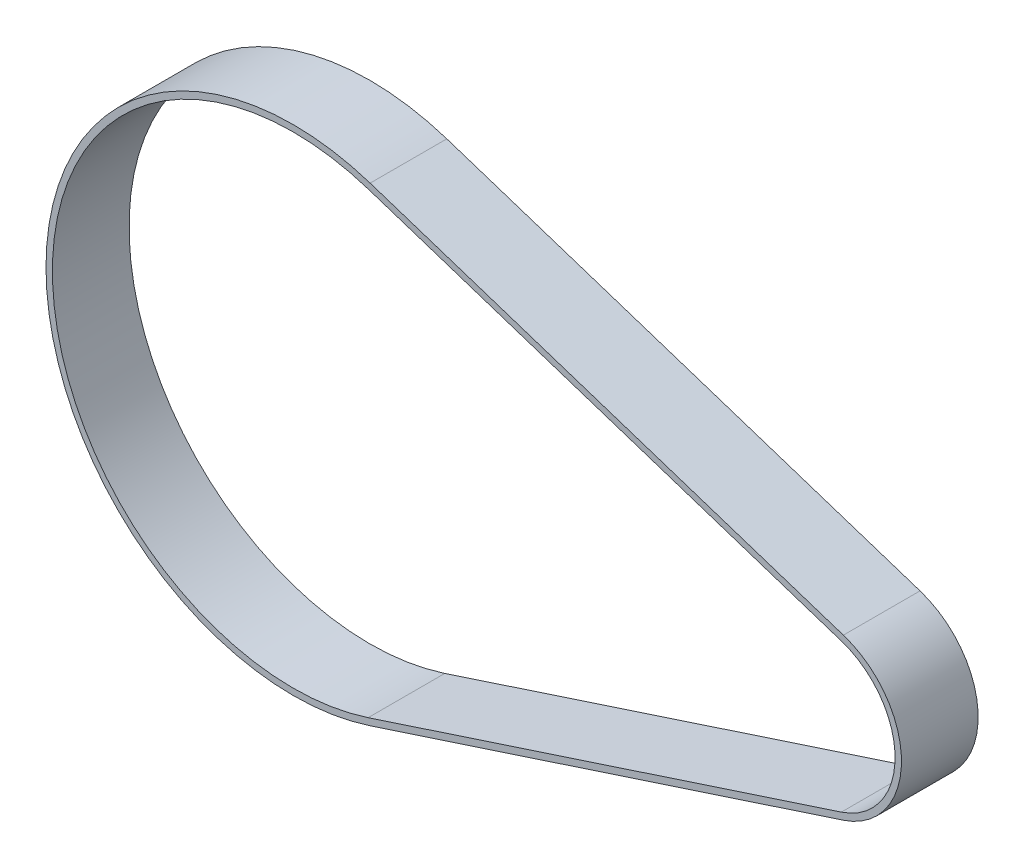
from build123d import *

# Parameters (mm, degrees)
SALIENTE_EXTRUIR1_DEPTH = 6


with BuildPart() as part:
    # Croquis1 → Saliente-Extruir1 (new body)
    with BuildSketch(Plane.XY):
        with BuildLine():
            Line((43.052439024, -6.27275809), (6.017378049, -18.390586217))
            ThreePointArc((6.017378049, -18.390586217), (-19.35, 0), (6.017378049, 18.390586217))
            Line((6.017378049, 18.390586217), (43.052439024, 6.27275809))
            ThreePointArc((43.052439024, 6.27275809), (47.6, 0), (43.052439024, -6.27275809))
        make_face()
        with BuildLine():
            Line((5.861890244, 17.915377271), (42.89695122, 5.797549143))
            ThreePointArc((42.89695122, 5.797549143), (47.1, 0), (42.89695122, -5.797549143))
            Line((42.89695122, -5.797549143), (5.861890244, -17.915377271))
            ThreePointArc((5.861890244, -17.915377271), (-18.85, 0), (5.861890244, 17.915377271))
        make_face(mode=Mode.SUBTRACT)
    extrude(amount=SALIENTE_EXTRUIR1_DEPTH)


solid = part.part
